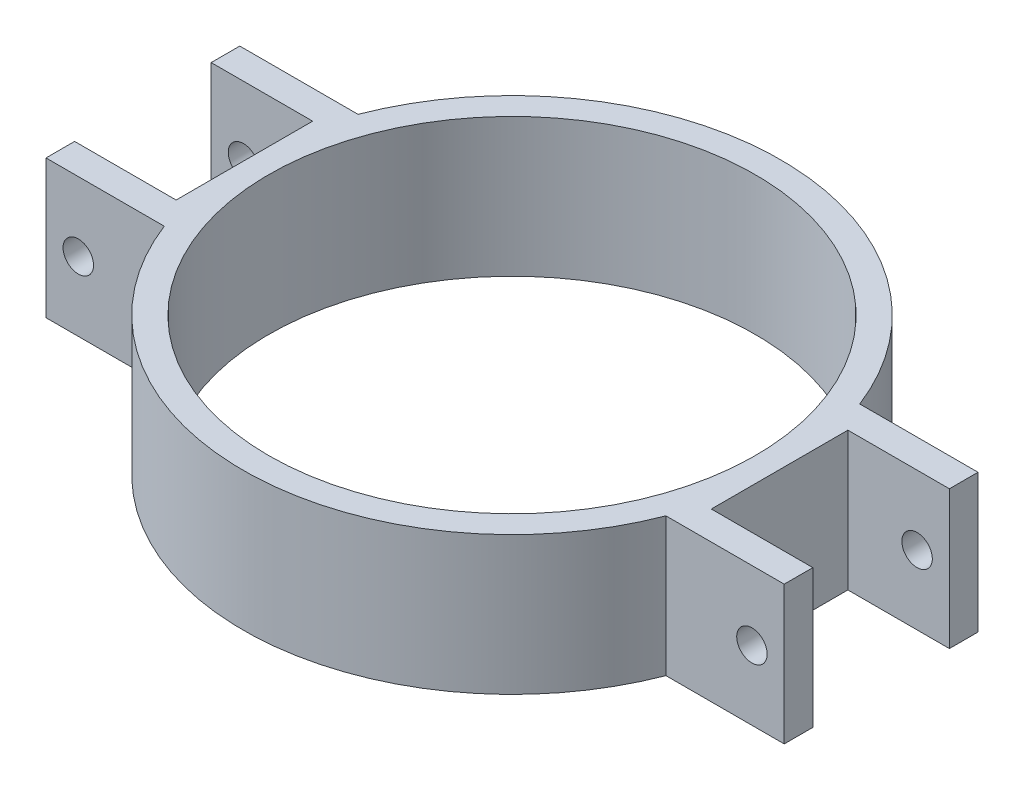
from build123d import *

# Parameters (mm, degrees)
SKETCH_1_R          = 26.37
EXTRUDE_1_DEPTH     = 15
SKETCH_2_R          = 1.65
CUT_EXTRUDE_1_DEPTH = 23


with BuildPart() as part:
    # 草图1 → 凸台-拉伸1 (new body)
    with BuildSketch(Plane(origin=(0, 0, 0), x_dir=(1, 0, 0), z_dir=(0, 1, 0))):
        with BuildLine():
            Line((-40, 7.4), (-29, 7.4))
            Line((-29, 7.4), (-29, -7.4))
            Line((-29, -7.4), (-40, -7.4))
            Line((-40, -7.4), (-40, -10.5))
            Line((-40, -10.5), (-27.182523797, -10.5))
            ThreePointArc((-27.182523797, -10.5), (0, -29.14), (27.182523797, -10.5))
            Line((27.182523797, -10.5), (40, -10.5))
            Line((40, -10.5), (40, -7.4))
            Line((40, -7.4), (29, -7.4))
            Line((29, -7.4), (29, 7.4))
            Line((29, 7.4), (40, 7.4))
            Line((40, 7.4), (40, 10.5))
            Line((40, 10.5), (27.182523797, 10.5))
            ThreePointArc((27.182523797, 10.5), (0, 29.14), (-27.182523797, 10.5))
            Line((-27.182523797, 10.5), (-40, 10.5))
            Line((-40, 10.5), (-40, 7.4))
        make_face()
        Circle(SKETCH_1_R, mode=Mode.SUBTRACT)
    extrude(amount=EXTRUDE_1_DEPTH)

    # 草图2 → 切除-拉伸1 (cut)
    with BuildSketch(Plane(origin=(0, 0, -10.5), x_dir=(-1, 0, 0), z_dir=(0, 0, -1))):
        with Locations((36.5, 7.5)):
            Circle(SKETCH_2_R)
        with Locations((-36.5, 7.5)):
            Circle(SKETCH_2_R)
    extrude(amount=-CUT_EXTRUDE_1_DEPTH, mode=Mode.SUBTRACT)


solid = part.part
